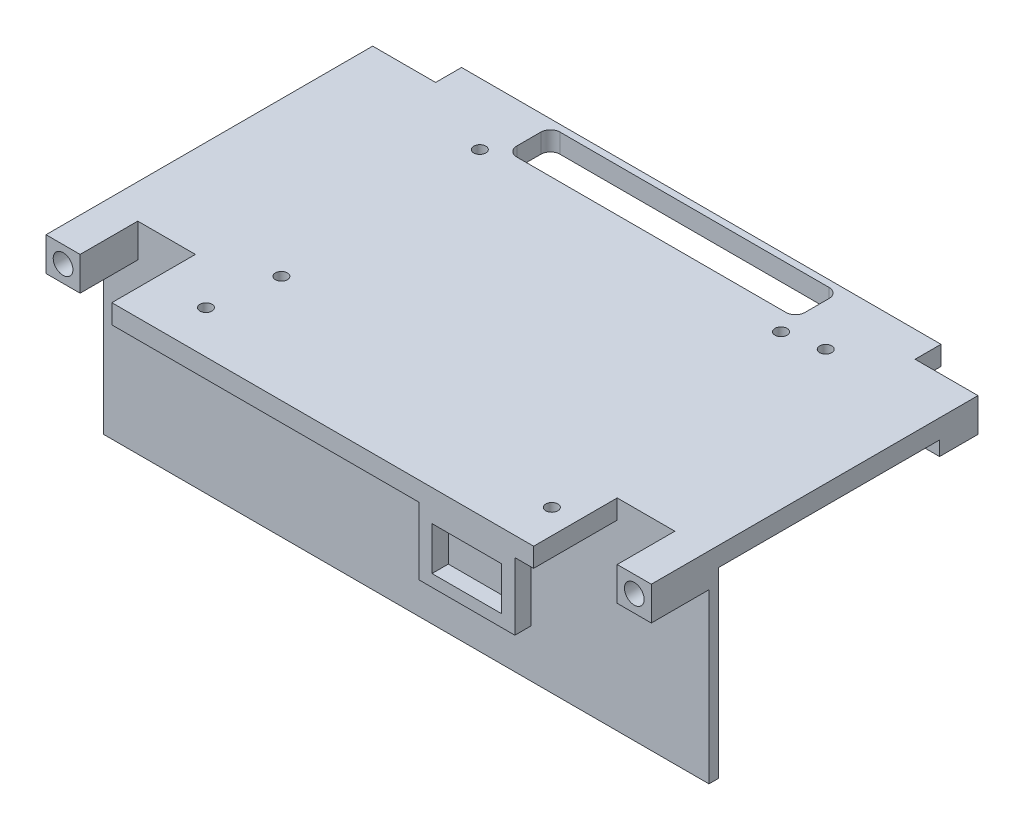
from build123d import *

# Parameters (mm, degrees)
BOSS_EXTRUDE1_DEPTH             = 4
SKETCH3_W                       = 7.1
SKETCH3_H                       = 8
BOSS_EXTRUDE3_DEPTH             = 3
SKETCH4_R                       = 2.05
CUT_EXTRUDE1_DEPTH              = 7
MIRROR2_COPY_1_SKETCH_W         = 7.1
MIRROR2_COPY_1_SKETCH_H         = 8
MIRROR2_COPY_1_DEPTH            = 3
MIRROR2_COPY_2_SKETCH_R         = 2.05
MIRROR2_COPY_2_DEPTH            = 7
SKETCH5_W                       = 60
SKETCH5_H                       = 9
CUT_EXTRUDE2_DEPTH              = 76.4917214
FILLET1_R                       = 2
SKETCH7_W                       = 111.8
SKETCH7_H                       = 1
CUT_EXTRUDE3_DEPTH              = 76.4917214
SKETCH8_W                       = 126
SKETCH8_H                       = 2
BOSS_EXTRUDE4_DEPTH             = 38
SKETCH9_W                       = 12
SKETCH9_H                       = 18
CUT_EXTRUDE4_DEPTH              = 10
SKETCH10_W                      = 7.1
SKETCH10_H                      = 4
BOSS_EXTRUDE5_DEPTH             = 3
SKETCH12_W                      = 1.5
SKETCH12_H                      = 4
BOSS_EXTRUDE6_DEPTH             = 2
SKETCH13_W                      = 40
SKETCH13_H                      = 2
BOSS_EXTRUDE7_DEPTH             = 38
SKETCH14_W                      = 1.5
SKETCH14_H                      = 4
BOSS_EXTRUDE8_DEPTH             = 1
BOSS_EXTRUDE9_REACH             = 85.744
BOSS_EXTRUDE9_DIRECTION_2_REACH = 85.744
SKETCH16_W                      = 20
SKETCH16_H                      = 14
SKETCH16_W_2                    = 14.5
SKETCH16_H_2                    = 9
BOSS_EXTRUDE10_DEPTH            = 4
SKETCH17_W                      = 12
SKETCH17_H                      = 18
CUT_EXTRUDE5_DEPTH              = 84.743656476
SKETCH18_W                      = 6
SKETCH18_H                      = 6
CUT_EXTRUDE6_DEPTH              = 86.632937588
SKETCH22_R                      = 1.25
CUT_EXTRUDE7_DEPTH              = 4
SKETCH25_W                      = 6
SKETCH25_H                      = 38
CUT_EXTRUDE11_DEPTH             = 10
SKETCH26_W                      = 5.701552738
SKETCH26_H                      = 30.562488548
SKETCH26_W_2                    = 6.53419365
SKETCH26_H_2                    = 28.524331859
CUT_EXTRUDE12_DEPTH             = 85.498520697
CUT_EXTRUDE12_DEPTH_BACK        = 85.498520697
SKETCH27_R                      = 1.25
CUT_EXTRUDE13_DEPTH             = 86.632937588
SKETCH28_W                      = 99.8
SKETCH28_H                      = 0.6
SKETCH28_W_2                    = 87.8
CUT_EXTRUDE14_DEPTH             = 86.632937588


with BuildPart() as part:
    # Sketch1 → Boss-Extrude1 (new body)
    with BuildSketch(Plane(origin=(0, 0, 0), x_dir=(1, 0, 0), z_dir=(0, 1, 0))):
        Polygon((-63, -34), (-55.9, -34), (-55.9, -41), (55.9, -41), (55.9, -34), (63, -34), (63, 34), (55.9, 34), (55.9, 41), (-55.9, 41), (-55.9, 34), (-63, 34), align=None)
    extrude(amount=BOSS_EXTRUDE1_DEPTH)

    # Sketch3 → Boss-Extrude3 (add)
    with BuildSketch(Plane.XZ):
        with Locations((-59.45, -30)):
            Rectangle(SKETCH3_W, SKETCH3_H)
    boss_extrude3 = extrude(amount=BOSS_EXTRUDE3_DEPTH)

    # Sketch4 → Cut-Extrude1 (cut)
    with BuildSketch(Plane(origin=(0, 0, -34), x_dir=(-1, 0, 0), z_dir=(0, 0, -1))):
        with Locations((59.45, 0.5)):
            Circle(SKETCH4_R)
    cut_extrude1 = extrude(amount=-CUT_EXTRUDE1_DEPTH, mode=Mode.SUBTRACT)

    # Mirror1: Boss-Extrude3, Cut-Extrude1 across plane
    add(boss_extrude3.mirror(Plane(origin=(0, 0, 0), x_dir=(0, 0, 1), z_dir=(1, 0, 0))))
    add(cut_extrude1.mirror(Plane(origin=(0, 0, 0), x_dir=(0, 0, 1), z_dir=(1, 0, 0))), mode=Mode.SUBTRACT)

    # Mirror2: Boss-Extrude3, Cut-Extrude1 across plane
    add(boss_extrude3.mirror(Plane.XY))
    add(cut_extrude1.mirror(Plane.XY), mode=Mode.SUBTRACT)

    # Mirror2 copy 1 sketch → Mirror2 copy 1 (add)
    with BuildSketch(Plane(origin=(0, 0, 0), x_dir=(-1, 0, 0), z_dir=(0, -1, 0))):
        with Locations((-59.45, -30)):
            Rectangle(MIRROR2_COPY_1_SKETCH_W, MIRROR2_COPY_1_SKETCH_H)
    extrude(amount=MIRROR2_COPY_1_DEPTH)

    # Mirror2 copy 2 sketch → Mirror2 copy 2 (cut)
    with BuildSketch(Plane.XY.offset(34)):
        with Locations((59.45, 0.5)):
            Circle(MIRROR2_COPY_2_SKETCH_R)
    extrude(amount=-MIRROR2_COPY_2_DEPTH, mode=Mode.SUBTRACT)

    # Sketch5 → Cut-Extrude2 (cut, through all)
    with BuildSketch(Plane(origin=(0, 4, 0), x_dir=(1, 0, 0), z_dir=(0, 1, 0))):
        with Locations((0, 33.5)):
            Rectangle(SKETCH5_W, SKETCH5_H)
    extrude(amount=-CUT_EXTRUDE2_DEPTH, mode=Mode.SUBTRACT)

    # Fillet1
    fillet1_edges = [part.edges().sort_by_distance(p)[0] for p in [
        (-30, 2, -29),
        (-30, 2, -38),
        (30, 2, -38),
        (30, 2, -29),
    ]]
    fillet(fillet1_edges, radius=FILLET1_R)

    # Sketch7 → Cut-Extrude3 (cut, through all)
    with BuildSketch(Plane(origin=(0, 4, 0), x_dir=(1, 0, 0), z_dir=(0, 1, 0))):
        with Locations((0, 40.5)):
            Rectangle(SKETCH7_W, SKETCH7_H)
        with Locations((0, -40.5)):
            Rectangle(SKETCH7_W, SKETCH7_H)
    extrude(amount=-CUT_EXTRUDE3_DEPTH, mode=Mode.SUBTRACT)

    # Sketch8 → Boss-Extrude4 (add)
    with BuildSketch(Plane.XZ):
        with Locations((0, 21)):
            Rectangle(SKETCH8_W, SKETCH8_H)
    extrude(amount=BOSS_EXTRUDE4_DEPTH)

    # Sketch9 → Cut-Extrude4 (cut)
    with BuildSketch(Plane(origin=(0, 4, 0), x_dir=(1, 0, 0), z_dir=(0, 1, 0))):
        with Locations((-49.9, -31)):
            Rectangle(SKETCH9_W, SKETCH9_H)
    extrude(amount=-CUT_EXTRUDE4_DEPTH, mode=Mode.SUBTRACT)

    # Sketch10 → Boss-Extrude5 (add)
    with BuildSketch(Plane.XZ.offset(3)):
        with Locations((-59.45, 24)):
            Rectangle(SKETCH10_W, SKETCH10_H)
        with Locations((59.45, 24)):
            Rectangle(SKETCH10_W, SKETCH10_H)
    extrude(amount=-BOSS_EXTRUDE5_DEPTH)

    # Sketch12 → Boss-Extrude6 (add)
    with BuildSketch(Plane.ZY.offset(56)):
        Polygon((22, -5.8), (22, -16.2), (24.7, -13.5), (24.7, -8.5), align=None)
        with Locations((23.35, -11)):
            Rectangle(SKETCH12_W, SKETCH12_H, mode=Mode.SUBTRACT)
        Polygon((22, -20.8), (22, -31.2), (24.7, -28.5), (24.7, -23.5), align=None)
        with Locations((23.35, -26)):
            Rectangle(SKETCH12_W, SKETCH12_H, mode=Mode.SUBTRACT)
    boss_extrude6 = extrude(amount=-BOSS_EXTRUDE6_DEPTH)

    # Mirror3: Boss-Extrude6 across plane
    add(boss_extrude6.mirror(Plane(origin=(-49.9, 0, 0), x_dir=(0, 0, 1), z_dir=(1, 0, 0))))

    # Sketch13 → Boss-Extrude7 (add)
    with BuildSketch(Plane.XZ):
        with Locations((0, -20.5)):
            Rectangle(SKETCH13_W, SKETCH13_H)
    extrude(amount=BOSS_EXTRUDE7_DEPTH)

    # Sketch14 → Boss-Extrude8 (add, symmetric)
    with BuildSketch(Plane(origin=(0, 0, 0), x_dir=(0, 0, -1), z_dir=(1, 0, 0))):
        Polygon((24.2, -8.5), (21.5, -5.8), (21.5, -16.2), (24.2, -13.5), align=None)
        with Locations((22.85, -11)):
            Rectangle(SKETCH14_W, SKETCH14_H, mode=Mode.SUBTRACT)
        Polygon((24.2, -28.5), (24.2, -23.5), (21.5, -20.8), (21.5, -31.2), align=None)
        with Locations((22.85, -26)):
            Rectangle(SKETCH14_W, SKETCH14_H, mode=Mode.SUBTRACT)
    extrude(amount=BOSS_EXTRUDE8_DEPTH, both=True)

    # Boss-Extrude9: up to this face of the body (flat: up to its plane)
    boss_extrude9_end = Plane(part.part.faces().sort_by_distance((-20, -19, -20.5))[0])
    # Sketch15 → Boss-Extrude9 (add, up to the picked face)
    with BuildSketch(Plane(origin=(0, 0, 0), x_dir=(0, 0, -1), z_dir=(1, 0, 0)), mode=Mode.PRIVATE) as boss_extrude9_sk1:
        Polygon((19.5, 0), (19.5, -5), (16.613248654, 0), align=None)
    boss_extrude9_tool1 = split(extrude(boss_extrude9_sk1.sketch, amount=-BOSS_EXTRUDE9_REACH, mode=Mode.PRIVATE), bisect_by=boss_extrude9_end, keep=Keep.BOTH, mode=Mode.PRIVATE)
    add(boss_extrude9_tool1.solids().sort_by(Axis((0, -1.666667, -18.53775), (-1, 0, 0)))[0])

    # Boss-Extrude9 direction 2: up to this face of the body (flat: up to its plane)
    boss_extrude9_direction_2_end = Plane(part.part.faces().sort_by_distance((20, -19, -20.5))[0])
    # Sketch15 → Boss-Extrude9 direction 2 (add, up to the picked face)
    with BuildSketch(Plane(origin=(0, 0, 0), x_dir=(0, 0, -1), z_dir=(1, 0, 0)), mode=Mode.PRIVATE) as boss_extrude9_direction_2_sk1:
        Polygon((19.5, 0), (19.5, -5), (16.613248654, 0), align=None)
    boss_extrude9_direction_2_tool1 = split(extrude(boss_extrude9_direction_2_sk1.sketch, amount=BOSS_EXTRUDE9_DIRECTION_2_REACH, mode=Mode.PRIVATE), bisect_by=boss_extrude9_direction_2_end, keep=Keep.BOTH, mode=Mode.PRIVATE)
    add(boss_extrude9_direction_2_tool1.solids().sort_by(Axis((0, -1.666667, -18.53775), (1, 0, 0)))[0])

    # Sketch16 → Boss-Extrude10 (add)
    with BuildSketch(Plane.XY.offset(40)):
        with Locations((30, -7)):
            Rectangle(SKETCH16_W, SKETCH16_H)
        with Locations((30, -7)):
            Rectangle(SKETCH16_W_2, SKETCH16_H_2, mode=Mode.SUBTRACT)
    extrude(amount=-BOSS_EXTRUDE10_DEPTH)

    # Sketch17 → Cut-Extrude5 (cut, through all)
    with BuildSketch(Plane.XZ):
        with Locations((49.9, 31)):
            Rectangle(SKETCH17_W, SKETCH17_H)
    extrude(amount=-CUT_EXTRUDE5_DEPTH, mode=Mode.SUBTRACT)

    # Sketch18 → Cut-Extrude6 (cut, through all)
    with BuildSketch(Plane(origin=(0, 4, 0), x_dir=(1, 0, 0), z_dir=(0, 1, 0))):
        with Locations((52.9, 37)):
            Rectangle(SKETCH18_W, SKETCH18_H)
        with Locations((-52.9, 37)):
            Rectangle(SKETCH18_W, SKETCH18_H)
    extrude(amount=-CUT_EXTRUDE6_DEPTH, mode=Mode.SUBTRACT)

    # Sketch22 → Cut-Extrude7 (cut)
    with BuildSketch(Plane(origin=(0, 4, 0), x_dir=(1, 0, 0), z_dir=(0, 1, 0))):
        with Locations(Location((31, 25, 0), (0, 0, 270))):
            Circle(SKETCH22_R)
        with Locations(Location((-31, -17, 0), (0, 0, 270))):
            Circle(SKETCH22_R)
    extrude(amount=-CUT_EXTRUDE7_DEPTH, mode=Mode.SUBTRACT)

    # Sketch25 → Cut-Extrude11 (cut)
    with BuildSketch(Plane(origin=(0, 0, -21.5), x_dir=(-1, 0, 0), z_dir=(0, 0, -1))):
        with Locations((-17, -19)):
            Rectangle(SKETCH25_W, SKETCH25_H)
        with Locations((17, -19)):
            Rectangle(SKETCH25_W, SKETCH25_H)
    extrude(amount=-CUT_EXTRUDE11_DEPTH, mode=Mode.SUBTRACT)

    # Sketch26 → Cut-Extrude12 (cut, two sides)
    with BuildSketch(Plane.ZY.offset(1)) as cut_extrude12_sk:
        with Locations((-24.350776369, -21.081244274)):
            Rectangle(SKETCH26_W, SKETCH26_H)
        with Locations((25.267096825, -20.06216593)):
            Rectangle(SKETCH26_W_2, SKETCH26_H_2)
    extrude(amount=CUT_EXTRUDE12_DEPTH, mode=Mode.SUBTRACT)
    extrude(cut_extrude12_sk.sketch, amount=-CUT_EXTRUDE12_DEPTH_BACK, mode=Mode.SUBTRACT)

    # Sketch27 → Cut-Extrude13 (cut, through all)
    with BuildSketch(Plane(origin=(0, 4, 0), x_dir=(1, 0, 0), z_dir=(0, 1, 0))):
        with Locations(Location((-33.2, 26.5, 0), (0, 0, 270))):
            Circle(SKETCH27_R)
        with Locations(Location((-33.2, -30.5, 0), (0, 0, 270))):
            Circle(SKETCH27_R)
        with Locations(Location((38.8, -30.5, 0), (0, 0, 270))):
            Circle(SKETCH27_R)
        with Locations(Location((38.8, 26.5, 0), (0, 0, 270))):
            Circle(SKETCH27_R)
    extrude(amount=-CUT_EXTRUDE13_DEPTH, mode=Mode.SUBTRACT)

    # Sketch28 → Cut-Extrude14 (cut, through all)
    with BuildSketch(Plane(origin=(0, 4, 0), x_dir=(1, 0, 0), z_dir=(0, 1, 0))):
        with Locations((0, 39.7)):
            Rectangle(SKETCH28_W, SKETCH28_H)
        with Locations((0, -39.7)):
            Rectangle(SKETCH28_W_2, SKETCH28_H)
    extrude(amount=-CUT_EXTRUDE14_DEPTH, mode=Mode.SUBTRACT)


solid = part.part
